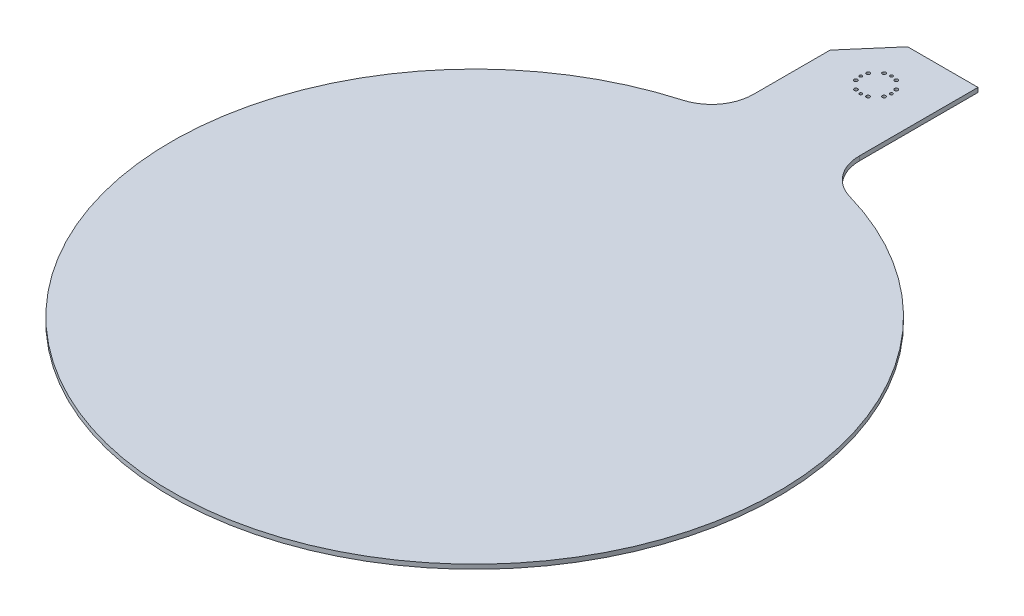
from build123d import *

# Parameters (mm, degrees)
BOSS_EXTRUDE1_DEPTH = 3.175
SKETCH20_R          = 1.25
SKETCH20_R_2        = 1
CUT_EXTRUDE1_DEPTH  = 4.175
CUT_EXTRUDE2_DEPTH  = 4.175


with BuildPart() as part:
    # Sketch1 → Boss-Extrude1 (new body)
    with BuildSketch(Plane(origin=(-1.297967049, 0, -318.957650502), x_dir=(1, 0, 0), z_dir=(0, 1, 0))):
        with BuildLine():
            Line((-41.969554108, 375.107652622), (34.230445892, 375.107652622))
            Line((34.230445892, 375.107652622), (34.230445892, 270.154369347))
            ThreePointArc((34.230445892, 270.154369347), (40.275943564, 252.093864975), (55.975900438, 241.312343077))
            ThreePointArc((55.975900438, 241.312343077), (-3.869554108, -185.292347378), (-63.715008653, 241.312343077))
            ThreePointArc((-63.715008653, 241.312343077), (-48.015051779, 252.093864975), (-41.969554108, 270.154369347))
            Line((-41.969554108, 270.154369347), (-41.969554108, 375.107652622))
        make_face()
    extrude(amount=BOSS_EXTRUDE1_DEPTH)

    # Sketch20 → Cut-Extrude1 (cut, through all)
    with BuildSketch(Plane(origin=(0, 3.175, 0), x_dir=(1, 0, 0), z_dir=(0, 1, 0))):
        with Locations((-15.257093255, 634.683461631)):
            Circle(SKETCH20_R)
        with Locations((-16.167521157, 639.065303124)):
            Circle(SKETCH20_R_2)
        with Locations((-15.257093255, 643.447144618)):
            Circle(SKETCH20_R)
        with Locations((-5.167521157, 628.065303124)):
            Circle(SKETCH20_R_2)
        with Locations((-9.549362651, 628.975731026)):
            Circle(SKETCH20_R)
        with Locations((-0.785679663, 628.975731026)):
            Circle(SKETCH20_R)
        with Locations((-9.549362651, 649.154875222)):
            Circle(SKETCH20_R)
        with Locations((-5.167521157, 650.065303124)):
            Circle(SKETCH20_R_2)
        with Locations((-0.785679663, 649.154875222)):
            Circle(SKETCH20_R)
        with Locations((4.922050941, 643.447144618)):
            Circle(SKETCH20_R)
        with Locations((5.832478843, 639.065303124)):
            Circle(SKETCH20_R_2)
        with Locations((4.922050941, 634.683461631)):
            Circle(SKETCH20_R)
    extrude(amount=-CUT_EXTRUDE1_DEPTH, mode=Mode.SUBTRACT)

    # Sketch21 → Cut-Extrude2 (cut, through all)
    with BuildSketch(Plane(origin=(0, 3.175, 0), x_dir=(1, 0, 0), z_dir=(0, 1, 0))):
        Polygon((32.932478843, 694.065303124), (-43.267521157, 694.065303124), (-43.267521157, 674.065303124), (-43.267521157, 644.143456202), (-17.515896333, 674.065303124), (32.932478843, 674.065303124), align=None)
    extrude(amount=-CUT_EXTRUDE2_DEPTH, mode=Mode.SUBTRACT)


solid = part.part
